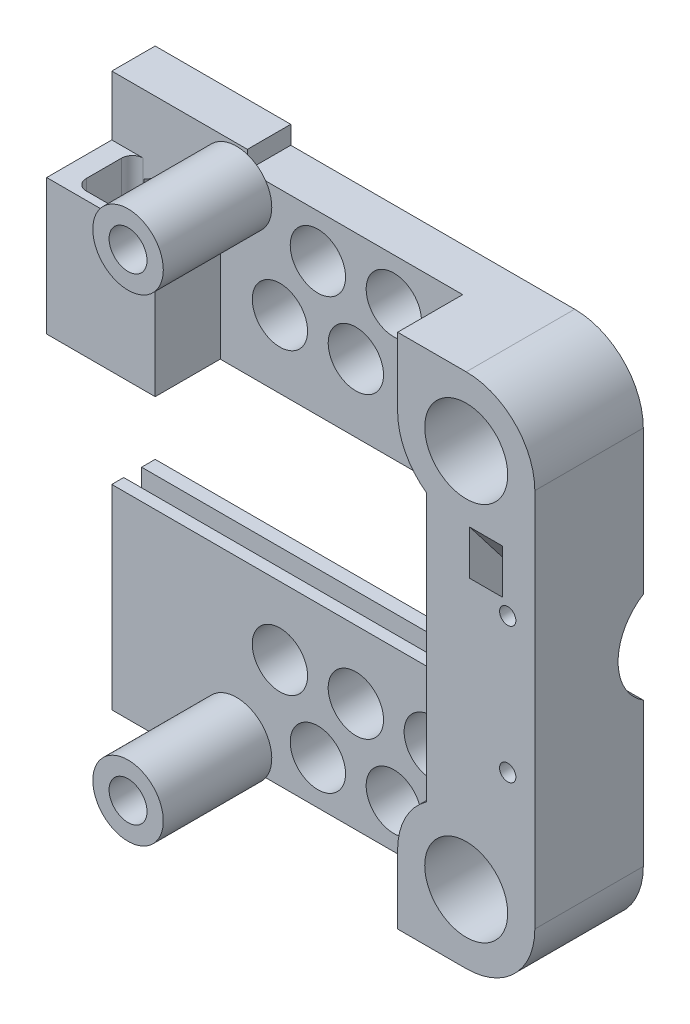
from build123d import *

# Parameters (mm, degrees)
ESBO_O1_R                  = 7.65
RESSALTO_EXTRUS_O1_DEPTH   = 20
ESBO_O2_W                  = 25
ESBO_O2_H                  = 20
RESSALTO_EXTRUS_O2_DEPTH   = 51
CORTE_EXTRUS_O1_DEPTH      = 78
CORTE_EXTRUS_O4_DEPTH      = 12
ESBO_O6_R                  = 1.5
CORTE_EXTRUS_O6_DEPTH      = 13
CORTE_EXTRUS_O6_DEPTH_BACK = 9
ESBO_O7_R                  = 10
CORTE_EXTRUS_O7_DEPTH      = 8
ESBO_O9_W                  = 12.4
ESBO_O9_H                  = 10.5
CORTE_EXTRUS_O8_DEPTH      = 25
RESSALTO_EXTRUS_O3_DEPTH   = 15.5
ESBO_O12_R                 = 1.65
CORTE_EXTRUS_O9_DEPTH      = 10
CORTE_EXTRUS_O11_DEPTH     = 2
ESBO_O16_R                 = 6.5
ESBO_O16_R_2               = 3.5
RESSALTO_EXTRUS_O4_DEPTH   = 20
CORTE_EXTRUS_O13_DEPTH     = 6
ESBO_O18_R                 = 5.1
CORTE_EXTRUS_O14_DEPTH     = 10


with BuildPart() as part:
    # Esboço1 → Ressalto-extrusão1 (new body)
    with BuildSketch(Plane.XY):
        with BuildLine():
            Line((12.65, 35), (12.65, -35))
            ThreePointArc((12.65, -35), (8.944900782, -43.944900782), (0, -47.65))
            Line((0, -47.65), (-72.35, -47.65))
            Line((-72.35, -47.65), (-72.35, 47.65))
            Line((-72.35, 47.65), (0, 47.65))
            ThreePointArc((0, 47.65), (8.944900782, 43.944900782), (12.65, 35))
        make_face()
        with Locations((0, 35)):
            Circle(ESBO_O1_R, mode=Mode.SUBTRACT)
        with Locations((0, -35)):
            Circle(ESBO_O1_R, mode=Mode.SUBTRACT)
    extrude(amount=RESSALTO_EXTRUS_O1_DEPTH)

    # Esboço2 → Ressalto-extrusão2 (add, symmetric)
    with BuildSketch(Plane(origin=(0, 0, 0), x_dir=(1, 0, 0), z_dir=(0, 1, 0))):
        with Locations((-64.85, -10)):
            Rectangle(ESBO_O2_W, ESBO_O2_H)
    extrude(amount=RESSALTO_EXTRUS_O2_DEPTH, both=True)

    # Esboço3 → Corte-extrusão1 (cut)
    with BuildSketch(Plane.ZY.offset(77.35)):
        Polygon((13.8, 15), (5.8, 15), (5.8, 20), (2.5, 20), (2.5, 15), (-3, 15), (-3, -15), (2.5, -15), (2.5, -20), (5.8, -20), (5.8, -15), (13.8, -15), align=None)
    extrude(amount=-CORTE_EXTRUS_O1_DEPTH, mode=Mode.SUBTRACT)

    # Esboço4 → Corte-extrusão4 (cut)
    with BuildSketch(Plane.XY.offset(20)):
        with BuildLine():
            Line((-77.35, 40), (-57.35, 40))
            Line((-57.35, 40), (-57.35, 15))
            Line((-57.35, 15), (-77.35, 15))
            Line((-77.35, 15), (-77.35, -51))
            Line((-77.35, -51), (-52.35, -51))
            Line((-52.35, -51), (-52.35, -47.65))
            Line((-52.35, -47.65), (-12.65, -47.65))
            Line((-12.65, -47.65), (-12.65, -35))
            ThreePointArc((-12.65, -35), (-11.247221879, -29.210138171), (-7.35, -24.704369859))
            Line((-7.35, -24.704369859), (-7.35, -0.323389166))
            Line((-7.35, -0.323389166), (-7.35, 24.704369859))
            ThreePointArc((-7.35, 24.704369859), (-11.247221879, 29.210138171), (-12.65, 35))
            Line((-12.65, 35), (-12.65, 47.65))
            Line((-12.65, 47.65), (-52.35, 47.65))
            Line((-52.35, 47.65), (-52.35, 51))
            Line((-52.35, 51), (-77.35, 51))
            Line((-77.35, 51), (-77.35, 40))
        make_face()
    extrude(amount=-CORTE_EXTRUS_O4_DEPTH, mode=Mode.SUBTRACT)

    # Esboço6 → Corte-extrusão6 (cut, two sides)
    with BuildSketch(Plane.XY.offset(8)) as corte_extrus_o6_sk:
        with Locations((7.65, 12.5)):
            Circle(ESBO_O6_R)
        with Locations((7.65, -12.5)):
            Circle(ESBO_O6_R)
    extrude(amount=CORTE_EXTRUS_O6_DEPTH, mode=Mode.SUBTRACT)
    extrude(corte_extrus_o6_sk.sketch, amount=-CORTE_EXTRUS_O6_DEPTH_BACK, mode=Mode.SUBTRACT)

    # Esboço7 → Corte-extrusão7 (cut)
    with BuildSketch(Plane(origin=(12.65, 0, 0), x_dir=(0, 0, -1), z_dir=(1, 0, 0))):
        with Locations((5.349094788, 0)):
            Circle(ESBO_O7_R)
    extrude(amount=-CORTE_EXTRUS_O7_DEPTH, mode=Mode.SUBTRACT)

    # Esboço9 → Corte-extrusão8 (cut)
    with BuildSketch(Plane(origin=(0, 40, 0), x_dir=(1, 0, 0), z_dir=(0, 1, 0))):
        with Locations((-67.35, -13.25)):
            Rectangle(ESBO_O9_W, ESBO_O9_H)
    extrude(amount=-CORTE_EXTRUS_O8_DEPTH, mode=Mode.SUBTRACT)

    # Esboço10 → Ressalto-extrusão3 (add)
    with BuildSketch(Plane(origin=(0, 40, 0), x_dir=(1, 0, 0), z_dir=(0, 1, 0))):
        with BuildLine():
            Line((-71.55, -8), (-73.55, -8))
            Line((-73.55, -8), (-73.55, -10))
            ThreePointArc((-73.55, -10), (-72.964213562, -8.585786438), (-71.55, -8))
        make_face()
        with BuildLine():
            Line((-61.15, -8), (-63.15, -8))
            ThreePointArc((-63.15, -8), (-61.735786438, -8.585786438), (-61.15, -10))
            Line((-61.15, -10), (-61.15, -8))
        make_face()
        with BuildLine():
            ThreePointArc((-71.55, -18.5), (-72.964213562, -17.914213562), (-73.55, -16.5))
            Line((-73.55, -16.5), (-73.55, -18.5))
            Line((-73.55, -18.5), (-71.55, -18.5))
        make_face()
        with BuildLine():
            Line((-61.15, -18.5), (-61.15, -16.5))
            ThreePointArc((-61.15, -16.5), (-61.735786438, -17.914213562), (-63.15, -18.5))
            Line((-63.15, -18.5), (-61.15, -18.5))
        make_face()
    extrude(amount=-RESSALTO_EXTRUS_O3_DEPTH)

    # Esboço12 → Corte-extrusão9 (cut)
    with BuildSketch(Plane.XY.offset(8)):
        with Locations((-54.35, -44)):
            Circle(ESBO_O12_R)
        with Locations((-54.35, 44)):
            Circle(ESBO_O12_R)
        with Locations((-68.55, 35)):
            Circle(ESBO_O12_R)
    extrude(amount=-CORTE_EXTRUS_O9_DEPTH, mode=Mode.SUBTRACT)

    # Esboço14 → Corte-extrusão11 (cut)
    with BuildSketch(Plane.XY.offset(8)):
        Polygon((-71.45, 36.674315781), (-71.45, 33.325684219), (-68.55, 31.651368439), (-65.65, 33.325684219), (-65.65, 36.674315781), (-68.55, 38.348631561), align=None)
    extrude(amount=-CORTE_EXTRUS_O11_DEPTH, mode=Mode.SUBTRACT)

    # Esboço16 → Ressalto-extrusão4 (add)
    with BuildSketch(Plane.XY.offset(8)):
        with Locations((-54.35, 44)):
            Circle(ESBO_O16_R)
        with Locations((-54.35, 44)):
            Circle(ESBO_O16_R_2, mode=Mode.SUBTRACT)
        with Locations((-54.35, -44)):
            Circle(ESBO_O16_R)
        with Locations((-54.35, -44)):
            Circle(ESBO_O16_R_2, mode=Mode.SUBTRACT)
    extrude(amount=RESSALTO_EXTRUS_O4_DEPTH)

    # Esboço17 → Corte-extrusão13 (cut)
    with BuildSketch(Plane.ZY.offset(-0.65)):
        Polygon((11.8, 4.376686724), (11.8, -3.75), (5, -3.75), (5, 3.75), (20, 23.182890138), (20, 15), align=None)
    extrude(amount=-CORTE_EXTRUS_O13_DEPTH, mode=Mode.SUBTRACT)

    # Esboço18 → Corte-extrusão14 (cut)
    with BuildSketch(Plane.XY.offset(8)):
        with Locations((-39.35, -39.65)):
            Circle(ESBO_O18_R)
        with Locations((-32.35, -27.525644347)):
            Circle(ESBO_O18_R)
        with Locations((-46.35, -27.525644347)):
            Circle(ESBO_O18_R)
        with Locations((-25.35, -39.65)):
            Circle(ESBO_O18_R)
        with Locations((-18.35, -27.525644347)):
            Circle(ESBO_O18_R)
        with Locations((-18.35, 27.525644347)):
            Circle(ESBO_O18_R)
        with Locations((-25.35, 39.65)):
            Circle(ESBO_O18_R)
        with Locations((-46.35, 27.525644347)):
            Circle(ESBO_O18_R)
        with Locations((-32.35, 27.525644347)):
            Circle(ESBO_O18_R)
        with Locations((-39.35, 39.65)):
            Circle(ESBO_O18_R)
    extrude(amount=-CORTE_EXTRUS_O14_DEPTH, mode=Mode.SUBTRACT)


solid = part.part
